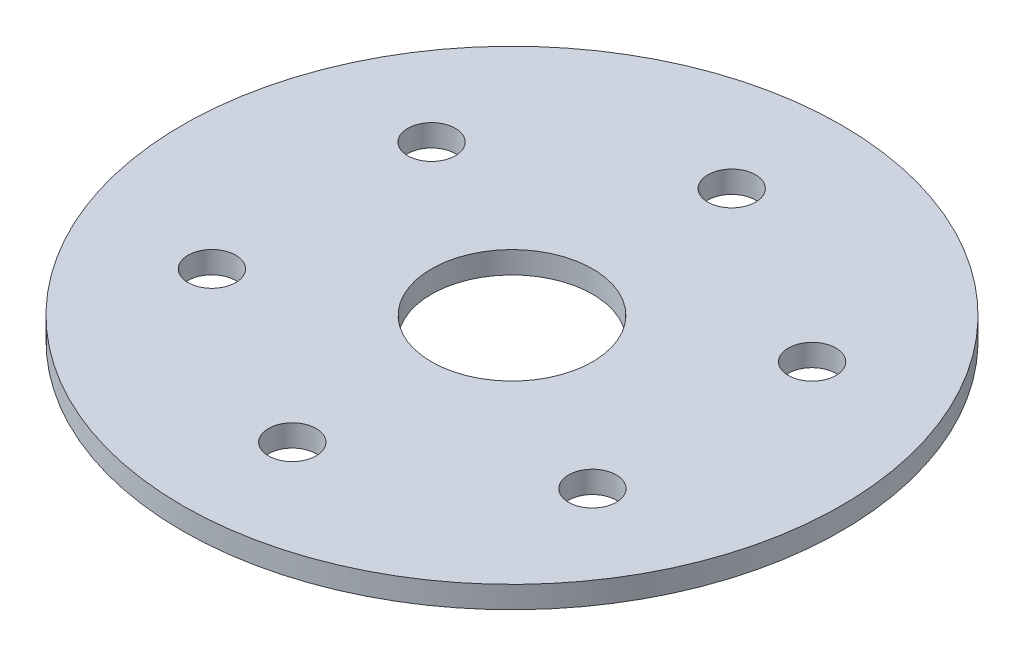
from build123d import *

# Parameters (mm, degrees)
CROQUIS1_R              = 45
CROQUIS1_R_2            = 11
SALIENTE_EXTRUIR1_DEPTH = 3
CROQUIS2_R              = 3.25
CORTAR_EXTRUIR1_DEPTH   = 4


with BuildPart() as part:
    # Croquis1 → Saliente-Extruir1 (new body)
    with BuildSketch(Plane(origin=(0, 0, 0), x_dir=(1, 0, 0), z_dir=(0, 1, 0))):
        Circle(CROQUIS1_R)
        Circle(CROQUIS1_R_2, mode=Mode.SUBTRACT)
    extrude(amount=SALIENTE_EXTRUIR1_DEPTH)

    # Croquis2 → Cortar-Extruir1 (cut, through all)
    with BuildSketch(Plane(origin=(0, 3, 0), x_dir=(1, 0, 0), z_dir=(0, 1, 0))):
        with Locations((0, 30)):
            Circle(CROQUIS2_R)
        with Locations((25.980762114, 15)):
            Circle(CROQUIS2_R)
        with Locations((25.980762114, -15)):
            Circle(CROQUIS2_R)
        with Locations((0, -30)):
            Circle(CROQUIS2_R)
        with Locations((-25.980762114, -15)):
            Circle(CROQUIS2_R)
        with Locations((-25.980762114, 15)):
            Circle(CROQUIS2_R)
    extrude(amount=-CORTAR_EXTRUIR1_DEPTH, mode=Mode.SUBTRACT)


solid = part.part
